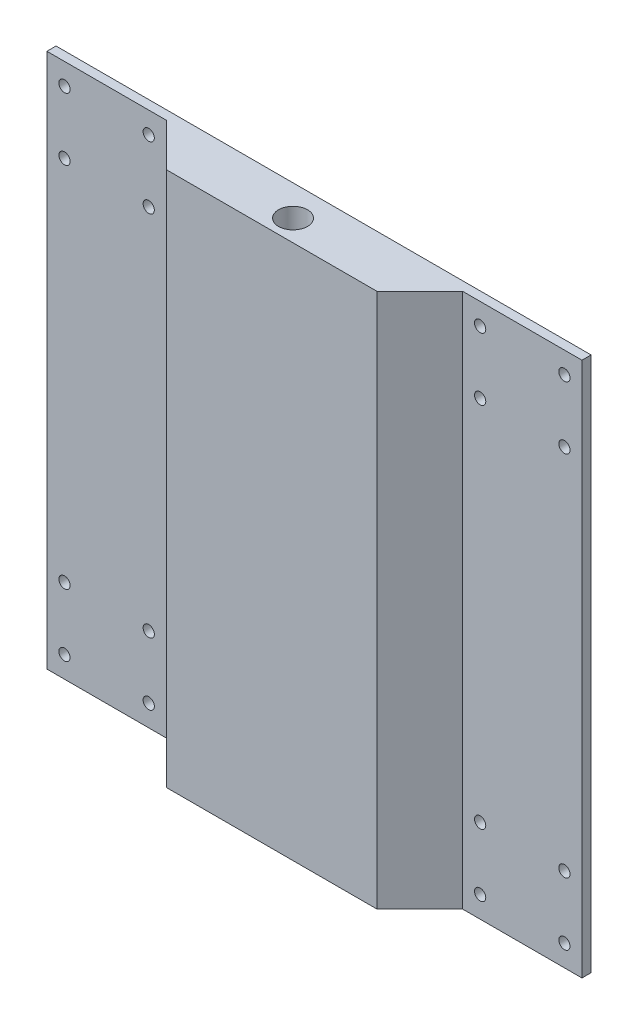
from build123d import *

# Parameters (mm, degrees)
SKETCH1_W                    = 152.4
SKETCH1_H                    = 152.4
BOSS_EXTRUDE1_DEPTH          = 2.6
BOSS_EXTRUDE4_DEPTH          = 152.4
TAP_DRILL_FOR_M8_HELICOIL2_D = 8.25
SKETCH2_R                    = 1.6
CUT_EXTRUDE1_DEPTH           = 3.6


with BuildPart() as part:
    # Sketch1 → Boss-Extrude1 (new body)
    with BuildSketch(Plane.XY):
        with Locations((76.2, 76.2)):
            Rectangle(SKETCH1_W, SKETCH1_H)
    extrude(amount=BOSS_EXTRUDE1_DEPTH)

    # Sketch8 → Boss-Extrude4 (add, through all)
    with BuildSketch(Plane(origin=(0, 152.4, 0), x_dir=(1, 0, 0), z_dir=(0, 1, 0))):
        Polygon((34, -2.6), (46.2, -14.8), (106.2, -14.8), (118.4, -2.6), align=None)
    extrude(amount=-BOSS_EXTRUDE4_DEPTH)

    # Tap Drill for M8 Helicoil2 (through all)
    with Locations(Plane(origin=(0, 152.4, 0), x_dir=(1, 0, 0), z_dir=(0, 1, 0))):
        with Locations((76.2, -8.7)):
            Hole(TAP_DRILL_FOR_M8_HELICOIL2_D / 2)

    # Sketch2 → Cut-Extrude1 (cut, through all)
    with BuildSketch(Plane.XY.offset(2.6)):
        with Locations((5, 128.5)):
            Circle(SKETCH2_R)
        with Locations((29, 146.3)):
            Circle(SKETCH2_R)
        with Locations((5, 146.3)):
            Circle(SKETCH2_R)
        with Locations((29, 128.5)):
            Circle(SKETCH2_R)
        with Locations((123.4, 146.3)):
            Circle(SKETCH2_R)
        with Locations((147.4, 146.3)):
            Circle(SKETCH2_R)
        with Locations((147.4, 128.5)):
            Circle(SKETCH2_R)
        with Locations((123.4, 128.5)):
            Circle(SKETCH2_R)
        with Locations((123.4, 23.9)):
            Circle(SKETCH2_R)
        with Locations((147.4, 23.9)):
            Circle(SKETCH2_R)
        with Locations((147.4, 6.1)):
            Circle(SKETCH2_R)
        with Locations((123.4, 6.1)):
            Circle(SKETCH2_R)
        with Locations((5, 23.9)):
            Circle(SKETCH2_R)
        with Locations((29, 23.9)):
            Circle(SKETCH2_R)
        with Locations((29, 6.1)):
            Circle(SKETCH2_R)
        with Locations((5, 6.1)):
            Circle(SKETCH2_R)
    extrude(amount=-CUT_EXTRUDE1_DEPTH, mode=Mode.SUBTRACT)


solid = part.part
